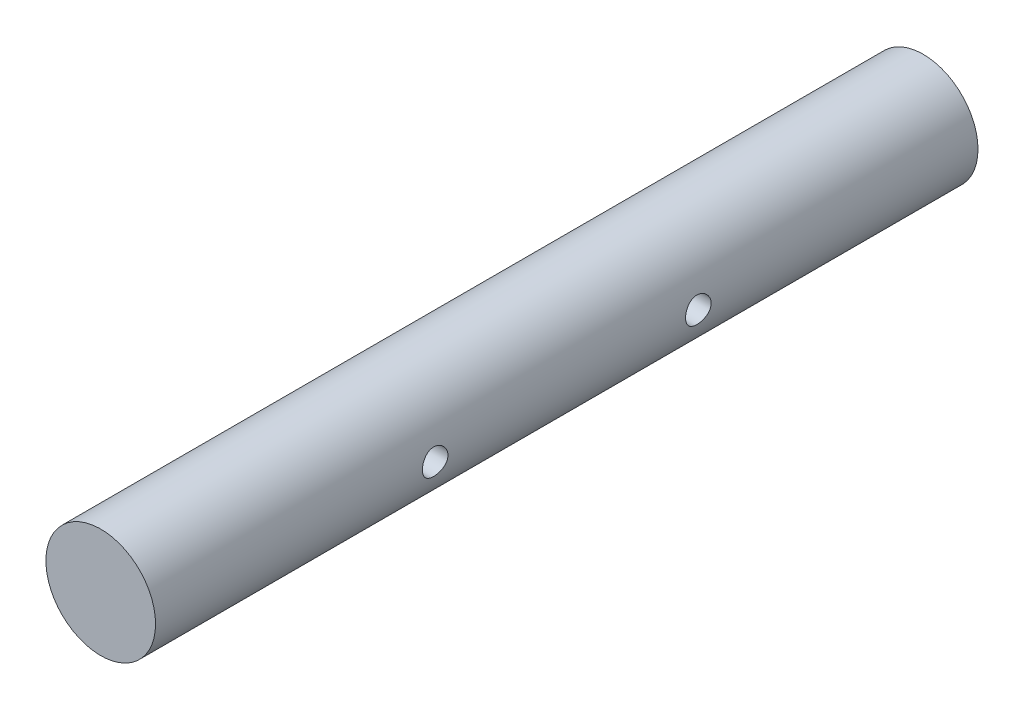
from build123d import *

# Parameters (mm, degrees)
SKETCH1_R               = 30
BOSS_EXTRUDE1_DEPTH     = 225
SKETCH2_R               = 7
CUT_EXTRUDE1_DEPTH      = 31
CUT_EXTRUDE1_DEPTH_BACK = 31


with BuildPart() as part:
    # Sketch1 → Boss-Extrude1 (new body, symmetric)
    with BuildSketch(Plane.XY):
        Circle(SKETCH1_R)
    extrude(amount=BOSS_EXTRUDE1_DEPTH, both=True)

    # Sketch2 → Cut-Extrude1 (cut, two sides)
    with BuildSketch(Plane(origin=(0, 0, 0), x_dir=(0, 0, -1), z_dir=(1, 0, 0))) as cut_extrude1_sk:
        with Locations((72, 0)):
            Circle(SKETCH2_R)
        with Locations((-72, 0)):
            Circle(SKETCH2_R)
    extrude(amount=CUT_EXTRUDE1_DEPTH, mode=Mode.SUBTRACT)
    extrude(cut_extrude1_sk.sketch, amount=-CUT_EXTRUDE1_DEPTH_BACK, mode=Mode.SUBTRACT)


solid = part.part
